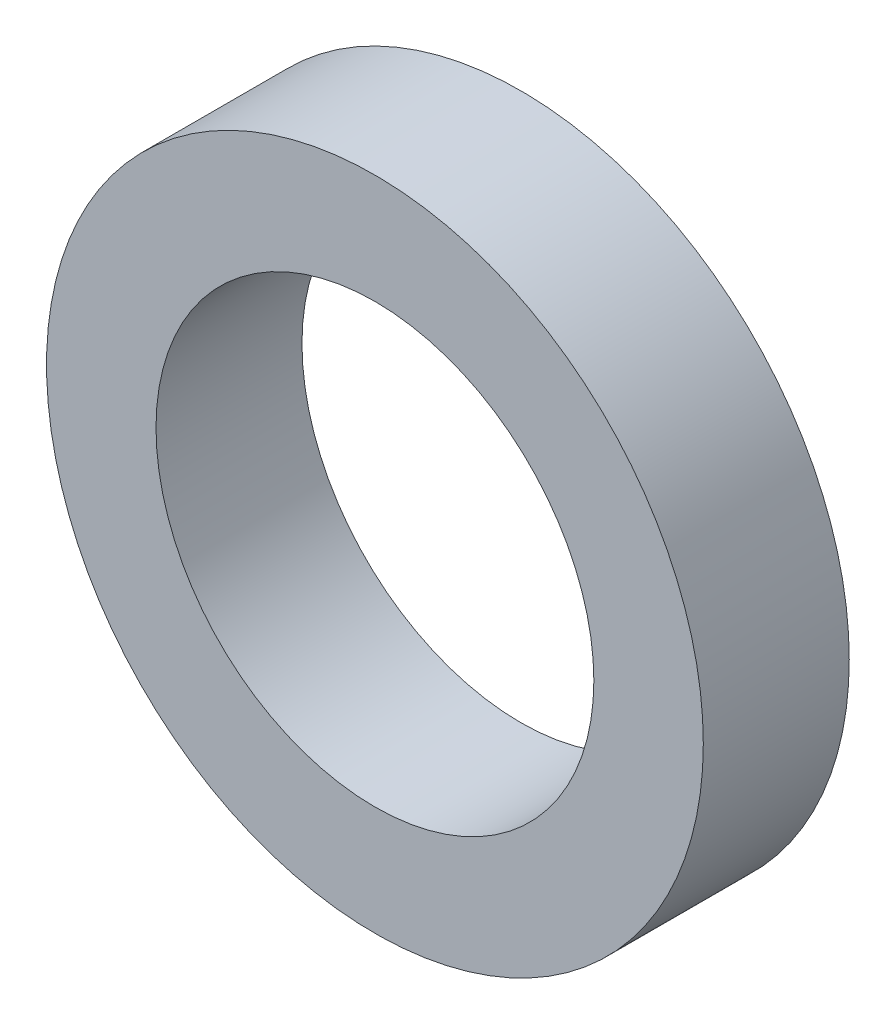
from build123d import *

# Parameters (mm, degrees)
SKETCH_1_R      = 9
SKETCH_1_R_2    = 6
EXTRUDE_1_DEPTH = 4


with BuildPart() as part:
    # 草图1 → 凸台-拉伸1 (new body)
    with BuildSketch(Plane.XY):
        Circle(SKETCH_1_R)
        Circle(SKETCH_1_R_2, mode=Mode.SUBTRACT)
    extrude(amount=EXTRUDE_1_DEPTH)


solid = part.part
